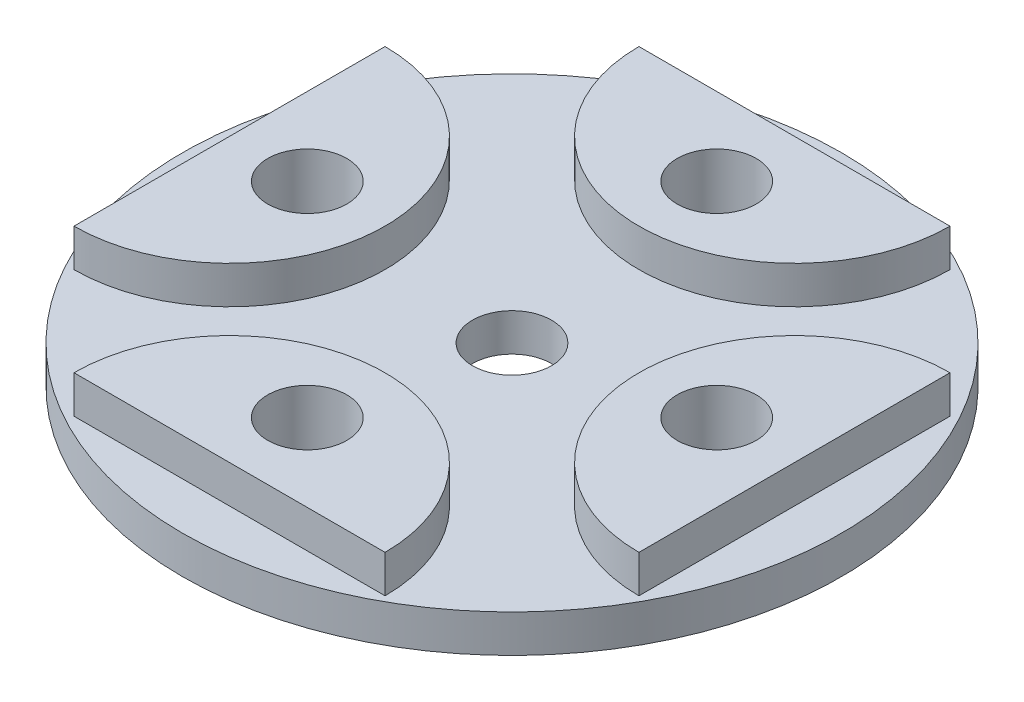
from build123d import *

# Parameters (mm, degrees)
SKETCH4_R           = 17.5
SKETCH4_R_2         = 2.1
BOSS_EXTRUDE1_DEPTH = 2
BOSS_EXTRUDE2_DEPTH = 4
SKETCH5_R           = 2.1
CUT_EXTRUDE2_DEPTH  = 5


with BuildPart() as part:
    # Sketch4 → Boss-Extrude1 (new body)
    with BuildSketch(Plane(origin=(0, 0, 0), x_dir=(1, 0, 0), z_dir=(0, 1, 0))):
        Circle(SKETCH4_R)
        Circle(SKETCH4_R_2, mode=Mode.SUBTRACT)
    extrude(amount=BOSS_EXTRUDE1_DEPTH)

    # Sketch1 → Boss-Extrude2 (add)
    with BuildSketch(Plane(origin=(0, 0, 0), x_dir=(1, 0, 0), z_dir=(0, 1, 0))):
        with BuildLine():
            Line((-8.26, 15), (8.26, 15))
            ThreePointArc((8.26, 15), (0, 6.74), (-8.26, 15))
        make_face()
        with BuildLine():
            Line((15, 8.26), (15, -8.26))
            ThreePointArc((15, -8.26), (6.74, 0), (15, 8.26))
        make_face()
        with BuildLine():
            Line((8.26, -15), (-8.26, -15))
            ThreePointArc((-8.26, -15), (0, -6.74), (8.26, -15))
        make_face()
        with BuildLine():
            Line((-15, -8.26), (-15, 8.26))
            ThreePointArc((-15, 8.26), (-6.74, 0), (-15, -8.26))
        make_face()
    extrude(amount=BOSS_EXTRUDE2_DEPTH)

    # Sketch5 → Cut-Extrude2 (cut, through all)
    with BuildSketch(Plane(origin=(0, 4, 0), x_dir=(1, 0, 0), z_dir=(0, 1, 0))):
        with Locations((0, 10.87)):
            Circle(SKETCH5_R)
        with Locations((10.87, 0)):
            Circle(SKETCH5_R)
        with Locations((0, -10.87)):
            Circle(SKETCH5_R)
        with Locations((-10.87, 0)):
            Circle(SKETCH5_R)
    extrude(amount=-CUT_EXTRUDE2_DEPTH, mode=Mode.SUBTRACT)


solid = part.part
